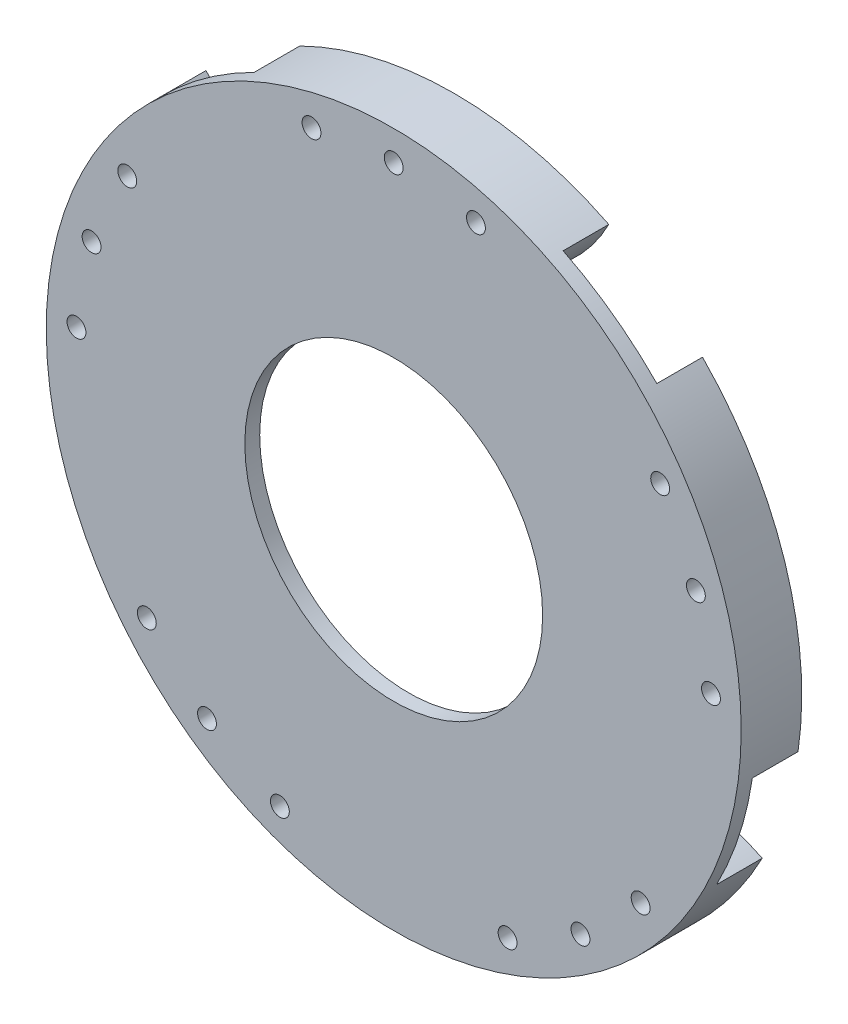
from build123d import *
from build123d.topology import SkipClean

# Parameters (mm, degrees)
SKETCH1_R                   = 35
BOSS_EXTRUDE1_DEPTH         = 1.5
BOSS_EXTRUDE2_START         = 4.6
BOSS_EXTRUDE2_DEPTH         = 4.6
SKETCH4_R                   = 0.95
CUT_EXTRUDE2_DEPTH          = 50.871935996
CIRPATTERN5_COUNT           = 2
CIRPATTERN5_ANGLE           = 15
CIRPATTERN6_COUNT           = 2
CIRPATTERN6_ANGLE           = 15
CIRPATTERN1_COUNT           = 5
CIRPATTERN1_COPY_1_SKETCH_R = 0.95
CIRPATTERN1_COPY_1_DEPTH    = 50.871935996
CIRPATTERN1_COPY_2_SKETCH_R = 0.95
CIRPATTERN1_COPY_2_DEPTH    = 50.871935996
CIRPATTERN1_COPY_3_SKETCH_R = 0.95
CIRPATTERN1_COPY_3_DEPTH    = 50.871935996
CIRPATTERN1_COPY_4_SKETCH_R = 0.95
CIRPATTERN1_COPY_4_DEPTH    = 50.871935996
CIRPATTERN1_COPY_5_SKETCH_R = 0.95
CIRPATTERN1_COPY_5_DEPTH    = 50.871935996
CIRPATTERN1_COPY_6_SKETCH_R = 0.95
CIRPATTERN1_COPY_6_DEPTH    = 50.871935996
CIRPATTERN1_COPY_7_SKETCH_R = 0.95
CIRPATTERN1_COPY_7_DEPTH    = 50.871935996
CIRPATTERN1_COPY_8_SKETCH_R = 0.95
CIRPATTERN1_COPY_8_DEPTH    = 50.871935996
SKETCH3_R                   = 15
CUT_EXTRUDE1_DEPTH          = 50.871935996


with BuildPart() as part:
    # Sketch1 → Boss-Extrude1 (new body)
    with BuildSketch(Plane.XY):
        Circle(SKETCH1_R)
    extrude(amount=BOSS_EXTRUDE1_DEPTH)

    # Sketch2 → Boss-Extrude2 (add)
    with SkipClean():  # the faces are left unmerged after this step: merging them gives an invalid solid
        with BuildSketch(Plane(origin=(0, 0, 0), x_dir=(-1, 0, 0), z_dir=(0, 0, -1)).offset(BOSS_EXTRUDE2_START)):
            with BuildLine():
                ThreePointArc((-15.56390888, 31.34907878), (0, 21.85), (15.56390888, 31.34907878))
                ThreePointArc((15.56390888, 31.34907878), (0, 35), (-15.56390888, 31.34907878))
            make_face()
        boss_extrude2 = extrude(amount=-BOSS_EXTRUDE2_DEPTH)

    # Sketch4 → Cut-Extrude2 (cut, through all)
    with SkipClean():  # the faces are left unmerged after this step: merging them gives an invalid solid
        with BuildSketch(Plane.XY.offset(1.5)):
            with Locations((0, 32)):
                Circle(SKETCH4_R)
        cut_extrude2 = extrude(amount=-CUT_EXTRUDE2_DEPTH, mode=Mode.SUBTRACT)

    # CirPattern5: Cut-Extrude2 ×2 about axis
    with SkipClean():  # the faces are left unmerged after this step: merging them gives an invalid solid
        cirpattern5_axis = Axis((0, 0, -88.99), (0, 0, 1))
        for i in range(1, CIRPATTERN5_COUNT):
            add(cut_extrude2.rotate(cirpattern5_axis, i * CIRPATTERN5_ANGLE / (CIRPATTERN5_COUNT - 1)), mode=Mode.SUBTRACT)

    # CirPattern6: Cut-Extrude2 ×2 about axis
    with SkipClean():  # the faces are left unmerged after this step: merging them gives an invalid solid
        cirpattern6_axis = Axis((0, 0, -88.99), (0, 0, -1))
        for i in range(1, CIRPATTERN6_COUNT):
            add(cut_extrude2.rotate(cirpattern6_axis, i * CIRPATTERN6_ANGLE / (CIRPATTERN6_COUNT - 1)), mode=Mode.SUBTRACT)

    # CirPattern1: Boss-Extrude2, Cut-Extrude2 ×5 about axis
    with SkipClean():  # the faces are left unmerged after this step: merging them gives an invalid solid
        cirpattern1_axis = Axis((0, 0, -88.99), (0, 0, 1))
        add([boss_extrude2.rotate(cirpattern1_axis, i * 360 / CIRPATTERN1_COUNT) for i in range(1, CIRPATTERN1_COUNT)])
        add([cut_extrude2.rotate(cirpattern1_axis, i * 360 / CIRPATTERN1_COUNT) for i in range(1, CIRPATTERN1_COUNT)], mode=Mode.SUBTRACT)

    # CirPattern1 copy 1 sketch → CirPattern1 copy 1 (cut, through all)
    with SkipClean():  # the faces are left unmerged after this step: merging them gives an invalid solid
        with BuildSketch(Plane(origin=(0, 0, 1.5), x_dir=(0.05233595624294324, 0.9986295347545739, 0), z_dir=(0, 0, 1))):
            with Locations((0, 32)):
                Circle(CIRPATTERN1_COPY_1_SKETCH_R)
        extrude(amount=-CIRPATTERN1_COPY_1_DEPTH, mode=Mode.SUBTRACT)

    # CirPattern1 copy 2 sketch → CirPattern1 copy 2 (cut, through all)
    with SkipClean():  # the faces are left unmerged after this step: merging them gives an invalid solid
        with BuildSketch(Plane(origin=(0, 0, 1.5), x_dir=(-0.9335804264972019, 0.3583679495452998, 0), z_dir=(0, 0, 1))):
            with Locations((0, 32)):
                Circle(CIRPATTERN1_COPY_2_SKETCH_R)
        extrude(amount=-CIRPATTERN1_COPY_2_DEPTH, mode=Mode.SUBTRACT)

    # CirPattern1 copy 3 sketch → CirPattern1 copy 3 (cut, through all)
    with SkipClean():  # the faces are left unmerged after this step: merging them gives an invalid solid
        with BuildSketch(Plane(origin=(0, 0, 1.5), x_dir=(-0.6293203910498371, -0.7771459614569711, 0), z_dir=(0, 0, 1))):
            with Locations((0, 32)):
                Circle(CIRPATTERN1_COPY_3_SKETCH_R)
        extrude(amount=-CIRPATTERN1_COPY_3_DEPTH, mode=Mode.SUBTRACT)

    # CirPattern1 copy 4 sketch → CirPattern1 copy 4 (cut, through all)
    with SkipClean():  # the faces are left unmerged after this step: merging them gives an invalid solid
        with BuildSketch(Plane(origin=(0, 0, 1.5), x_dir=(0.5446390350150274, -0.8386705679454238, 0), z_dir=(0, 0, 1))):
            with Locations((0, 32)):
                Circle(CIRPATTERN1_COPY_4_SKETCH_R)
        extrude(amount=-CIRPATTERN1_COPY_4_DEPTH, mode=Mode.SUBTRACT)

    # CirPattern1 copy 5 sketch → CirPattern1 copy 5 (cut, through all)
    with SkipClean():  # the faces are left unmerged after this step: merging them gives an invalid solid
        with BuildSketch(Plane(origin=(0, 0, 1.5), x_dir=(0.5446390350150276, 0.8386705679454236, 0), z_dir=(0, 0, 1))):
            with Locations((0, 32)):
                Circle(CIRPATTERN1_COPY_5_SKETCH_R)
        extrude(amount=-CIRPATTERN1_COPY_5_DEPTH, mode=Mode.SUBTRACT)

    # CirPattern1 copy 6 sketch → CirPattern1 copy 6 (cut, through all)
    with SkipClean():  # the faces are left unmerged after this step: merging them gives an invalid solid
        with BuildSketch(Plane(origin=(0, 0, 1.5), x_dir=(-0.6293203910498368, 0.7771459614569713, 0), z_dir=(0, 0, 1))):
            with Locations((0, 32)):
                Circle(CIRPATTERN1_COPY_6_SKETCH_R)
        extrude(amount=-CIRPATTERN1_COPY_6_DEPTH, mode=Mode.SUBTRACT)

    # CirPattern1 copy 7 sketch → CirPattern1 copy 7 (cut, through all)
    with SkipClean():  # the faces are left unmerged after this step: merging them gives an invalid solid
        with BuildSketch(Plane(origin=(0, 0, 1.5), x_dir=(-0.9335804264972021, -0.3583679495452995, 0), z_dir=(0, 0, 1))):
            with Locations((0, 32)):
                Circle(CIRPATTERN1_COPY_7_SKETCH_R)
        extrude(amount=-CIRPATTERN1_COPY_7_DEPTH, mode=Mode.SUBTRACT)

    # CirPattern1 copy 8 sketch → CirPattern1 copy 8 (cut, through all)
    with SkipClean():  # the faces are left unmerged after this step: merging them gives an invalid solid
        with BuildSketch(Plane(origin=(0, 0, 1.5), x_dir=(0.05233595624294293, -0.9986295347545739, 0), z_dir=(0, 0, 1))):
            with Locations((0, 32)):
                Circle(CIRPATTERN1_COPY_8_SKETCH_R)
        extrude(amount=-CIRPATTERN1_COPY_8_DEPTH, mode=Mode.SUBTRACT)

    # Sketch3 → Cut-Extrude1 (cut, through all)
    with SkipClean():  # the faces are left unmerged after this step: merging them gives an invalid solid
        with BuildSketch(Plane.XY.offset(1.5)):
            Circle(SKETCH3_R)
        extrude(amount=-CUT_EXTRUDE1_DEPTH, mode=Mode.SUBTRACT)


solid = part.part
